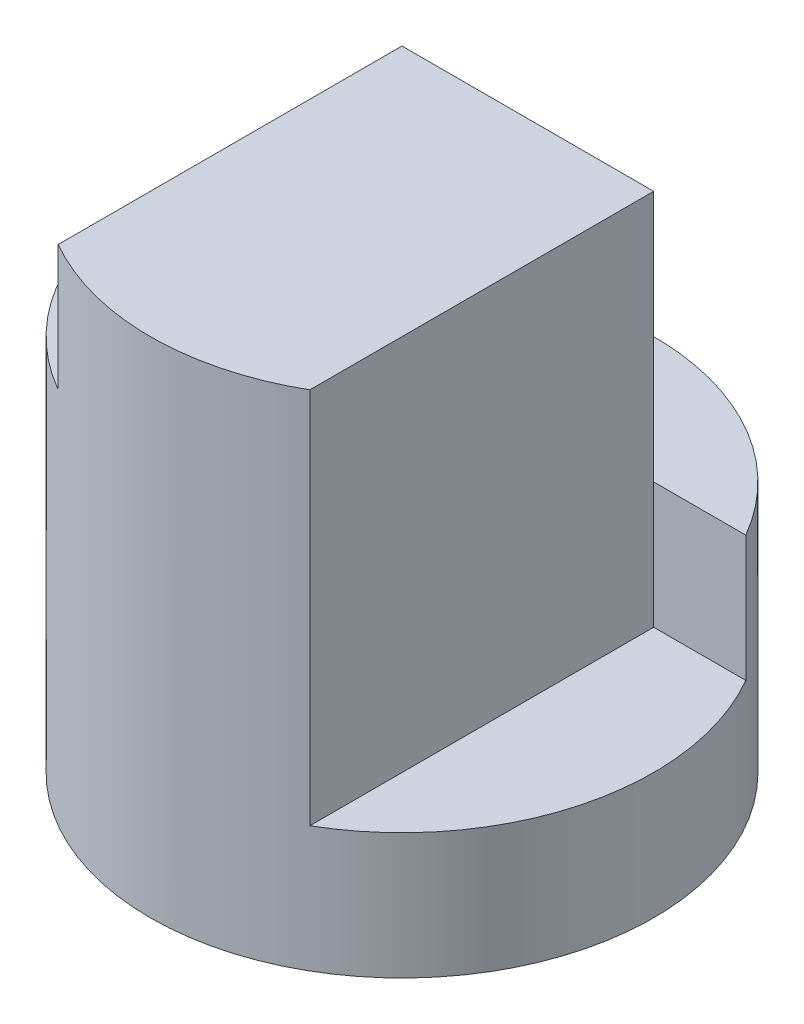
from build123d import *

# Parameters (mm, degrees)
SKETCH1_R               = 2
BOSS_EXTRUDE1_DEPTH     = 4
SKETCH2_W               = 1
SKETCH2_H               = 3
SKETCH2_H_2             = 1
CUT_EXTRUDE1_DEPTH      = 3
CUT_EXTRUDE1_DEPTH_BACK = 1
CUT_EXTRUDE2_DEPTH      = 2


with BuildPart() as part:
    # Sketch1 → Boss-Extrude1 (new body)
    with BuildSketch(Plane(origin=(0, 0, 0), x_dir=(1, 0, 0), z_dir=(0, 1, 0))):
        Circle(SKETCH1_R)
    extrude(amount=BOSS_EXTRUDE1_DEPTH)

    # Sketch2 → Cut-Extrude1 (cut, two sides)
    with BuildSketch(Plane.XY) as cut_extrude1_sk:
        with Locations((1.5, 2.5)):
            Rectangle(SKETCH2_W, SKETCH2_H)
        with Locations((-1.5, 3.5)):
            Rectangle(SKETCH2_W, SKETCH2_H_2)
    extrude(amount=CUT_EXTRUDE1_DEPTH, mode=Mode.SUBTRACT)
    extrude(cut_extrude1_sk.sketch, amount=-CUT_EXTRUDE1_DEPTH_BACK, mode=Mode.SUBTRACT)

    # Sketch3 → Cut-Extrude2 (cut)
    with BuildSketch(Plane(origin=(0, 4, 0), x_dir=(1, 0, 0), z_dir=(0, 1, 0))):
        with BuildLine():
            Line((-1.732050808, 1), (1.732050808, 1))
            ThreePointArc((1.732050808, 1), (0, 2), (-1.732050808, 1))
        make_face()
    extrude(amount=-CUT_EXTRUDE2_DEPTH, mode=Mode.SUBTRACT)


solid = part.part
